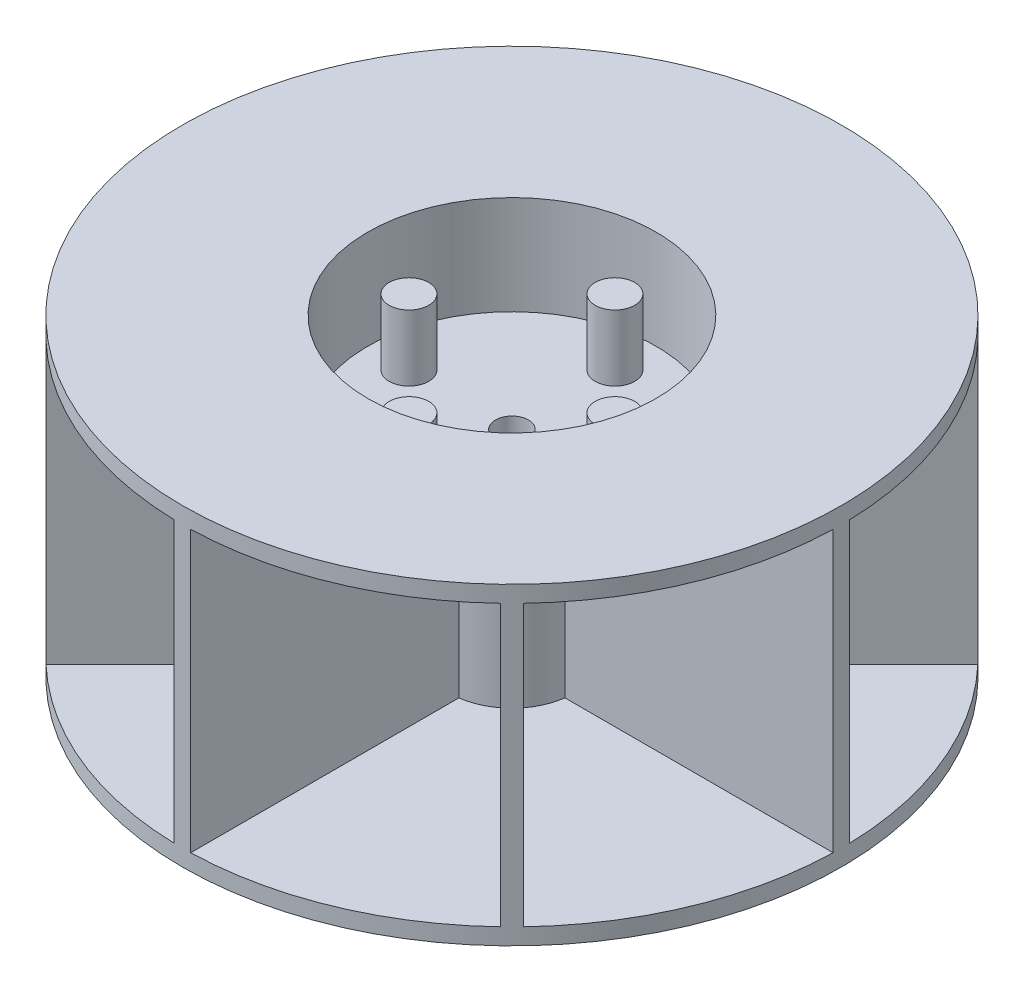
from build123d import *

# Parameters (mm, degrees)
SKETCH1_R            = 25.4
SKETCH1_R_2          = 3.175
BOSS_EXTRUDE1_DEPTH  = 1.27
SKETCH2_R            = 3.175
BOSS_EXTRUDE4_DEPTH  = 12.7
SKETCH5_R            = 11.1125
SKETCH5_R_2          = 3.175
BOSS_EXTRUDE6_DEPTH  = 2.54
SKETCH5_4_R          = 11.1125
BOSS_EXTRUDE7_DEPTH  = 8.89
SKETCH6_R            = 25.4
SKETCH6_R_2          = 11.1125
BOSS_EXTRUDE8_DEPTH  = 1.27
SKETCH7_R            = 1.524
BOSS_EXTRUDE9_DEPTH  = 5.08
BOSS_EXTRUDE10_START = -1.5875
SKETCH8_R            = 3.175
SKETCH8_R_2          = 1.27
BOSS_EXTRUDE10_DEPTH = 1.5875


with BuildPart() as part:
    # Sketch1 → Boss-Extrude1 (new body)
    with BuildSketch(Plane(origin=(0, 0, 0), x_dir=(1, 0, 0), z_dir=(0, 1, 0))):
        Circle(SKETCH1_R)
        Circle(SKETCH1_R_2, mode=Mode.SUBTRACT)
    extrude(amount=BOSS_EXTRUDE1_DEPTH)

    # Sketch2 → Boss-Extrude4 (add)
    with BuildSketch(Plane(origin=(0, 1.27, 0), x_dir=(1, 0, 0), z_dir=(0, 1, 0))):
        with BuildLine():
            ThreePointArc((0.635, 25.392061259), (0, 25.4), (-0.635, 25.392061259))
            Line((-0.635, 25.392061259), (-0.635, 4.719976827))
            ThreePointArc((-0.635, 4.719976827), (-1.822529847, 4.399976274), (-2.888514816, 3.786540428))
            Line((-2.888514816, 3.786540428), (-17.505885899, 18.403911511))
            ThreePointArc((-17.505885899, 18.403911511), (-17.960512242, 17.960512242), (-18.403911511, 17.505885899))
            Line((-18.403911511, 17.505885899), (-3.786540428, 2.888514816))
            ThreePointArc((-3.786540428, 2.888514816), (-4.399976274, 1.822529847), (-4.719976827, 0.635))
            Line((-4.719976827, 0.635), (-25.392061259, 0.635))
            ThreePointArc((-25.392061259, 0.635), (-25.4, 0), (-25.392061259, -0.635))
            Line((-25.392061259, -0.635), (-4.719976827, -0.635))
            ThreePointArc((-4.719976827, -0.635), (-4.399976274, -1.822529847), (-3.786540428, -2.888514816))
            Line((-3.786540428, -2.888514816), (-18.403911511, -17.505885899))
            ThreePointArc((-18.403911511, -17.505885899), (-17.960512242, -17.960512242), (-17.505885899, -18.403911511))
            Line((-17.505885899, -18.403911511), (-2.888514816, -3.786540428))
            ThreePointArc((-2.888514816, -3.786540428), (-1.822529847, -4.399976274), (-0.635, -4.719976827))
            Line((-0.635, -4.719976827), (-0.635, -25.392061259))
            ThreePointArc((-0.635, -25.392061259), (0, -25.4), (0.635, -25.392061259))
            Line((0.635, -25.392061259), (0.635, -4.719976827))
            ThreePointArc((0.635, -4.719976827), (1.822529847, -4.399976274), (2.888514816, -3.786540428))
            Line((2.888514816, -3.786540428), (17.505885899, -18.403911511))
            ThreePointArc((17.505885899, -18.403911511), (17.960512242, -17.960512242), (18.403911511, -17.505885899))
            Line((18.403911511, -17.505885899), (3.786540428, -2.888514816))
            ThreePointArc((3.786540428, -2.888514816), (4.399976274, -1.822529847), (4.719976827, -0.635))
            Line((4.719976827, -0.635), (25.392061259, -0.635))
            ThreePointArc((25.392061259, -0.635), (25.4, 0), (25.392061259, 0.635))
            Line((25.392061259, 0.635), (4.719976827, 0.635))
            ThreePointArc((4.719976827, 0.635), (4.399976274, 1.822529847), (3.786540428, 2.888514816))
            Line((3.786540428, 2.888514816), (18.403911511, 17.505885899))
            ThreePointArc((18.403911511, 17.505885899), (17.960512242, 17.960512242), (17.505885899, 18.403911511))
            Line((17.505885899, 18.403911511), (2.888514816, 3.786540428))
            ThreePointArc((2.888514816, 3.786540428), (1.822529847, 4.399976274), (0.635, 4.719976827))
            Line((0.635, 4.719976827), (0.635, 25.392061259))
        make_face()
        Circle(SKETCH2_R, mode=Mode.SUBTRACT)
    extrude(amount=BOSS_EXTRUDE4_DEPTH)

    # Sketch5 → Boss-Extrude6 (add)
    with BuildSketch(Plane(origin=(0, 13.97, 0), x_dir=(1, 0, 0), z_dir=(0, 1, 0))):
        Circle(SKETCH5_R)
        Circle(SKETCH5_R_2, mode=Mode.SUBTRACT)
    extrude(amount=BOSS_EXTRUDE6_DEPTH)

    # Sketch5_4 → Boss-Extrude7 (add)
    with BuildSketch(Plane(origin=(0, 13.97, 0), x_dir=(1, 0, 0), z_dir=(0, 1, 0))):
        with BuildLine():
            ThreePointArc((0.635, -12.684115066), (4.860079591, -11.733270063), (8.52001097, -9.418036582))
            Line((8.52001097, -9.418036582), (17.505885899, -18.403911511))
            ThreePointArc((17.505885899, -18.403911511), (17.960512242, -17.960512242), (18.403911511, -17.505885899))
            Line((18.403911511, -17.505885899), (9.418036582, -8.52001097))
            ThreePointArc((9.418036582, -8.52001097), (11.733270063, -4.860079591), (12.684115066, -0.635))
            Line((12.684115066, -0.635), (25.392061259, -0.635))
            ThreePointArc((25.392061259, -0.635), (25.4, 0), (25.392061259, 0.635))
            Line((25.392061259, 0.635), (12.684115066, 0.635))
            ThreePointArc((12.684115066, 0.635), (11.733270063, 4.860079591), (9.418036582, 8.52001097))
            Line((9.418036582, 8.52001097), (18.403911511, 17.505885899))
            ThreePointArc((18.403911511, 17.505885899), (17.960512242, 17.960512242), (17.505885899, 18.403911511))
            Line((17.505885899, 18.403911511), (8.52001097, 9.418036582))
            ThreePointArc((8.52001097, 9.418036582), (4.860079591, 11.733270063), (0.635, 12.684115066))
            Line((0.635, 12.684115066), (0.635, 25.392061259))
            ThreePointArc((0.635, 25.392061259), (0, 25.4), (-0.635, 25.392061259))
            Line((-0.635, 25.392061259), (-0.635, 12.684115066))
            ThreePointArc((-0.635, 12.684115066), (-4.860079591, 11.733270063), (-8.52001097, 9.418036582))
            Line((-8.52001097, 9.418036582), (-17.505885899, 18.403911511))
            ThreePointArc((-17.505885899, 18.403911511), (-17.960512242, 17.960512242), (-18.403911511, 17.505885899))
            Line((-18.403911511, 17.505885899), (-9.418036582, 8.52001097))
            ThreePointArc((-9.418036582, 8.52001097), (-11.733270063, 4.860079591), (-12.684115066, 0.635))
            Line((-12.684115066, 0.635), (-25.392061259, 0.635))
            ThreePointArc((-25.392061259, 0.635), (-25.4, 0), (-25.392061259, -0.635))
            Line((-25.392061259, -0.635), (-12.684115066, -0.635))
            ThreePointArc((-12.684115066, -0.635), (-11.733270063, -4.860079591), (-9.418036582, -8.52001097))
            Line((-9.418036582, -8.52001097), (-18.403911511, -17.505885899))
            ThreePointArc((-18.403911511, -17.505885899), (-17.960512242, -17.960512242), (-17.505885899, -18.403911511))
            Line((-17.505885899, -18.403911511), (-8.52001097, -9.418036582))
            ThreePointArc((-8.52001097, -9.418036582), (-4.860079591, -11.733270063), (-0.635, -12.684115066))
            Line((-0.635, -12.684115066), (-0.635, -25.392061259))
            ThreePointArc((-0.635, -25.392061259), (0, -25.4), (0.635, -25.392061259))
            Line((0.635, -25.392061259), (0.635, -12.684115066))
        make_face()
        Circle(SKETCH5_4_R, mode=Mode.SUBTRACT)
    extrude(amount=BOSS_EXTRUDE7_DEPTH)

    # Sketch6 → Boss-Extrude8 (add)
    with BuildSketch(Plane(origin=(0, 22.86, 0), x_dir=(1, 0, 0), z_dir=(0, 1, 0))):
        Circle(SKETCH6_R)
        Circle(SKETCH6_R_2, mode=Mode.SUBTRACT)
    extrude(amount=BOSS_EXTRUDE8_DEPTH)

    # Sketch7 → Boss-Extrude9 (add)
    with BuildSketch(Plane(origin=(0, 16.51, 0), x_dir=(1, 0, 0), z_dir=(0, 1, 0))):
        with Locations((7.9375, 0)):
            Circle(SKETCH7_R)
        with Locations((0, -7.9375)):
            Circle(SKETCH7_R)
        with Locations((-7.9375, 0)):
            Circle(SKETCH7_R)
        with Locations((0, 7.9375)):
            Circle(SKETCH7_R)
    extrude(amount=BOSS_EXTRUDE9_DEPTH)

    # Sketch8 → Boss-Extrude10 (add)
    with BuildSketch(Plane(origin=(0, 16.51, 0), x_dir=(1, 0, 0), z_dir=(0, 1, 0)).offset(BOSS_EXTRUDE10_START)):
        Circle(SKETCH8_R)
        Circle(SKETCH8_R_2, mode=Mode.SUBTRACT)
    extrude(amount=BOSS_EXTRUDE10_DEPTH)


solid = part.part
